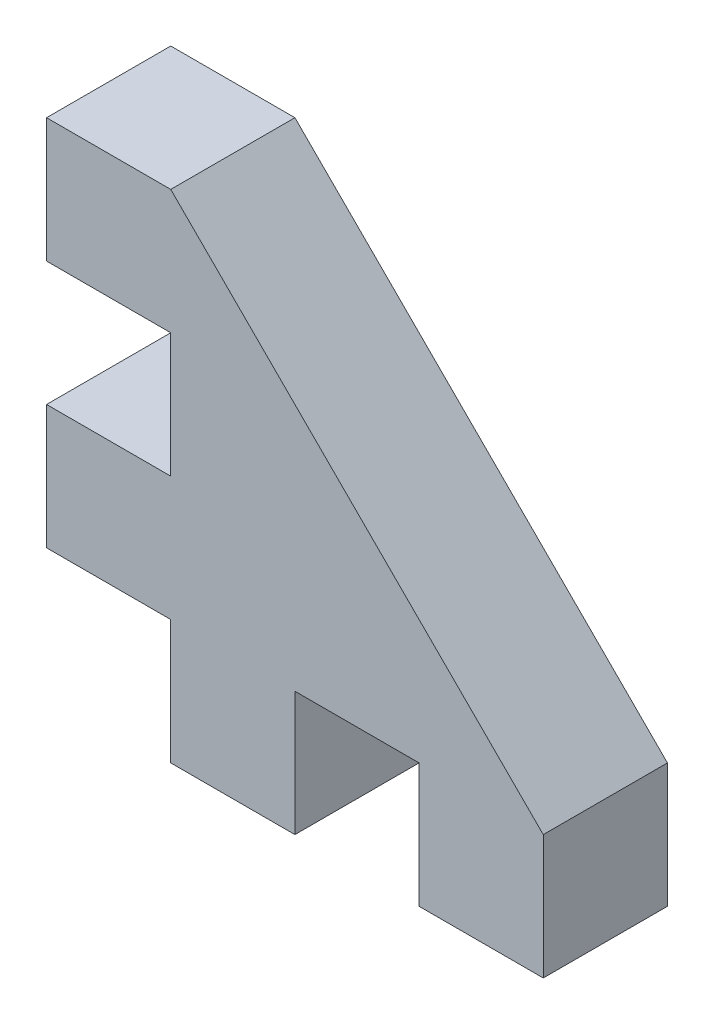
from build123d import *

# Parameters (mm, degrees)
ESQUISSE1_W             = 20
ESQUISSE1_H             = 20
BOSS_EXTRU_1_DEPTH      = 5
ESQUISSE2_W             = 5
ESQUISSE2_H             = 5
ENL_V_MAT_EXTRU_1_DEPTH = 5


with BuildPart() as part:
    # Esquisse1 → Boss.-Extru.1 (new body)
    with BuildSketch(Plane.XY):
        with Locations((-33.243041797, 4.26352657)):
            Rectangle(ESQUISSE1_W, ESQUISSE1_H)
    extrude(amount=BOSS_EXTRU_1_DEPTH)

    # Esquisse2 → Enlèv. mat.-Extru.1 (cut)
    with BuildSketch(Plane.XY.offset(5)):
        with Locations((-30.743041797, -3.23647343)):
            Rectangle(ESQUISSE2_W, ESQUISSE2_H)
        with Locations((-40.743041797, -3.23647343)):
            Rectangle(ESQUISSE2_W, ESQUISSE2_H)
        with Locations((-40.743041797, 6.76352657)):
            Rectangle(ESQUISSE2_W, ESQUISSE2_H)
        Polygon((-23.243041797, 14.26352657), (-38.243041797, 14.26352657), (-23.243041797, -0.73647343), align=None)
    extrude(amount=-ENL_V_MAT_EXTRU_1_DEPTH, mode=Mode.SUBTRACT)


solid = part.part
